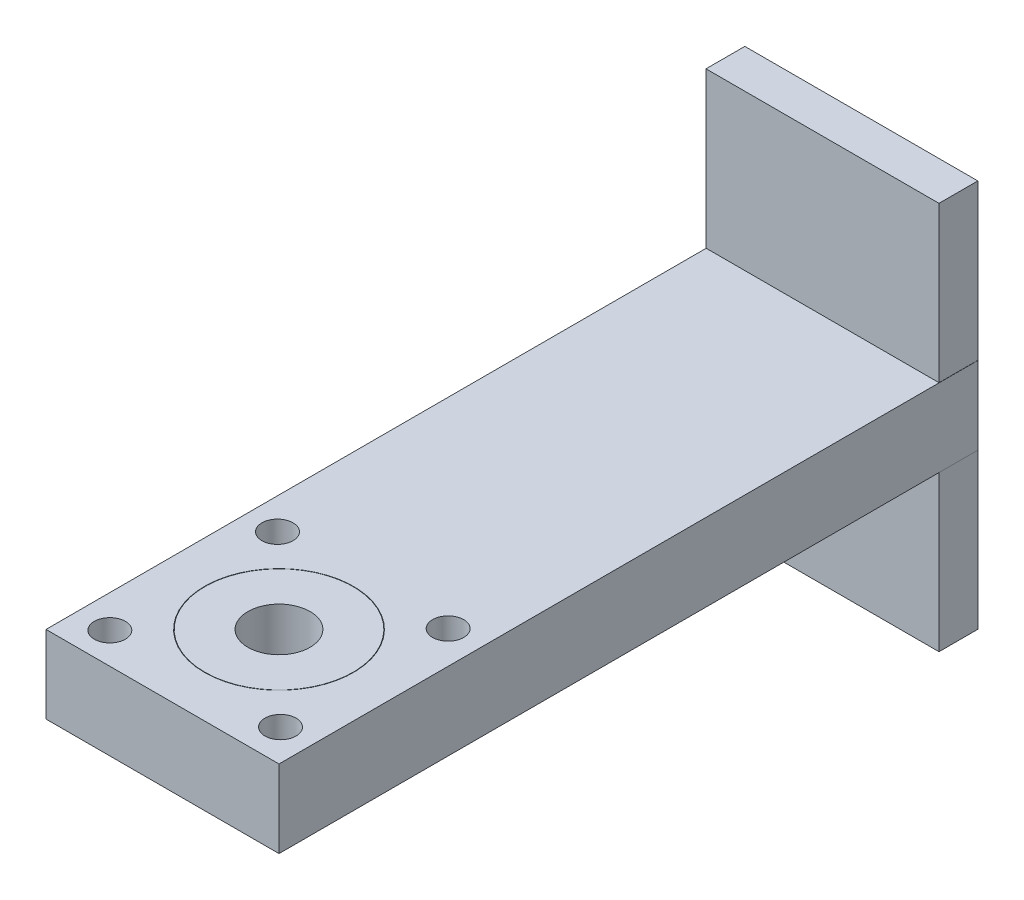
from build123d import *

# Parameters (mm, degrees)
SKETCH1_W           = 30
SKETCH1_H           = 30
BOSS_EXTRUDE1_DEPTH = 10
SKETCH2_R           = 9.6
SKETCH2_R_2         = 9.55
CUT_EXTRUDE1_DEPTH  = 7
SKETCH3_R           = 4
CUT_EXTRUDE2_DEPTH  = 7
SKETCH4_R           = 2
CUT_EXTRUDE3_DEPTH  = 10
CIRPATTERN1_COUNT   = 4
SKETCH5_W           = 30
SKETCH5_H           = 10
BOSS_EXTRUDE2_DEPTH = 60
SKETCH6_W           = 30
SKETCH6_H           = 50
BOSS_EXTRUDE3_DEPTH = 5


with BuildPart() as part:
    # Sketch1 → Boss-Extrude1 (new body)
    with BuildSketch(Plane(origin=(0, 0, 0), x_dir=(1, 0, 0), z_dir=(0, 1, 0))):
        Rectangle(SKETCH1_W, SKETCH1_H)
    extrude(amount=BOSS_EXTRUDE1_DEPTH)

    # Sketch2 → Cut-Extrude1 (cut)
    with BuildSketch(Plane(origin=(0, 10, 0), x_dir=(1, 0, 0), z_dir=(0, 1, 0))):
        Circle(SKETCH2_R)
        Circle(SKETCH2_R_2, mode=Mode.SUBTRACT)
    extrude(amount=-CUT_EXTRUDE1_DEPTH, mode=Mode.SUBTRACT)

    # Sketch3 → Cut-Extrude2 (cut)
    with BuildSketch(Plane(origin=(0, 10, 0), x_dir=(1, 0, 0), z_dir=(0, 1, 0))):
        Circle(SKETCH3_R)
    extrude(amount=-CUT_EXTRUDE2_DEPTH, mode=Mode.SUBTRACT)

    # Sketch4 → Cut-Extrude3 (cut)
    with BuildSketch(Plane(origin=(0, 10, 0), x_dir=(1, 0, 0), z_dir=(0, 1, 0))):
        with Locations((10.792349727, 10.987509758)):
            Circle(SKETCH4_R)
    cut_extrude3 = extrude(amount=-CUT_EXTRUDE3_DEPTH, mode=Mode.SUBTRACT)

    # CirPattern1: Cut-Extrude3 ×4 about axis
    cirpattern1_axis = Axis((0, 0, 0), (0, 1, 0))
    for i in range(1, CIRPATTERN1_COUNT):
        add(cut_extrude3.rotate(cirpattern1_axis, i * 360 / CIRPATTERN1_COUNT), mode=Mode.SUBTRACT)

    # Sketch5 → Boss-Extrude2 (add)
    with BuildSketch(Plane(origin=(0, 0, -15), x_dir=(-1, 0, 0), z_dir=(0, 0, -1))):
        with Locations((0, 5)):
            Rectangle(SKETCH5_W, SKETCH5_H)
    extrude(amount=BOSS_EXTRUDE2_DEPTH)

    # Sketch6 → Boss-Extrude3 (add)
    with BuildSketch(Plane(origin=(0, 0, -75), x_dir=(-1, 0, 0), z_dir=(0, 0, -1))):
        with Locations((0.023044467, 5)):
            Rectangle(SKETCH6_W, SKETCH6_H)
    extrude(amount=-BOSS_EXTRUDE3_DEPTH)


solid = part.part
